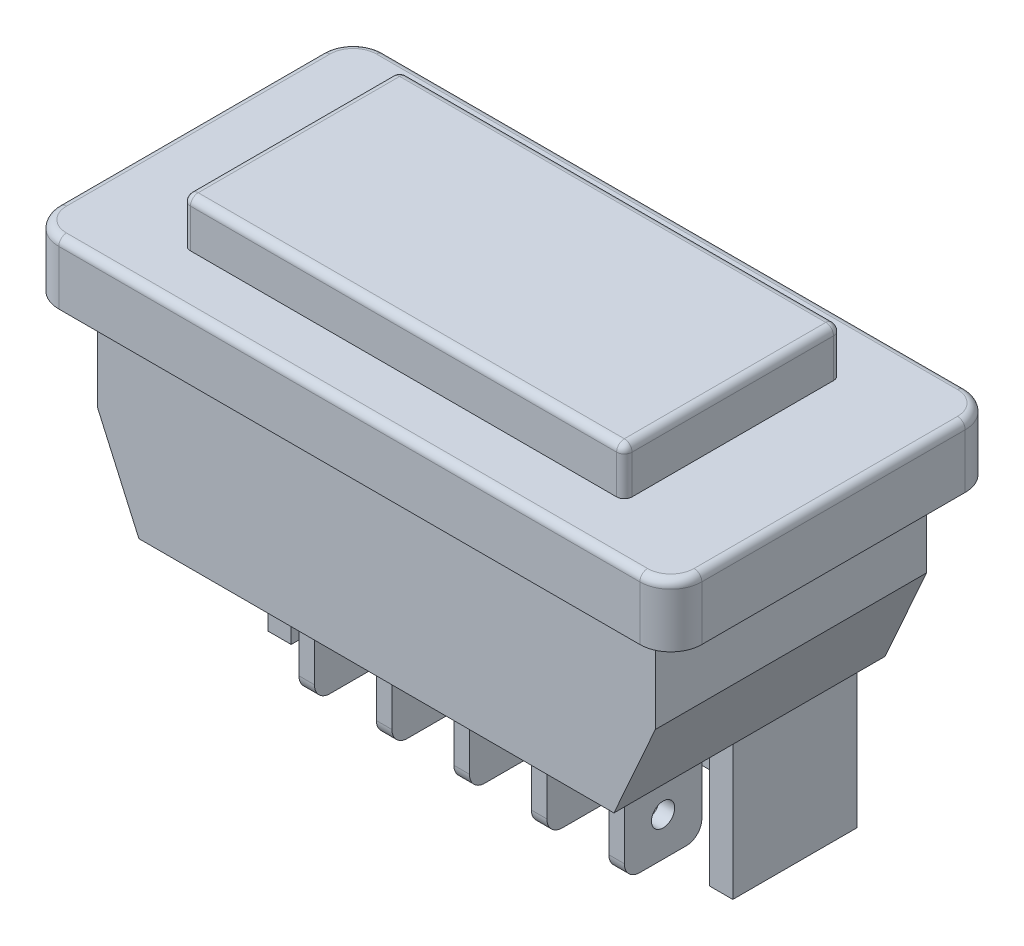
from build123d import *

# Parameters (mm, degrees)
SKETCH_1_W             = 41.5
SKETCH_1_H             = 21
EXTRUDE_1_DEPTH        = 4
FILLET_1_R             = 2
FILLET_2_R             = 0.5
SKETCH_2_W             = 28.5
SKETCH_2_H             = 14
EXTRUDE_2_DEPTH        = 3
FILLET_3_R             = 0.5
SKETCH_3_W             = 36
SKETCH_3_H             = 17.5
EXTRUDE_3_DEPTH        = 12
CHAMFER_1_SIZE         = 6
CHAMFER_1_SIZE2        = 2.671372112
CHAMFER_1_PART_2_SIZE  = 6
CHAMFER_1_PART_2_SIZE2 = 2.671372112
SKETCH_4_W             = 1
SKETCH_4_H             = 5
EXTRUDE_4_DEPTH        = 9
FILLET_4_R             = 1
SKETCH_5_R             = 0.75
CUT_EXTRUDE_1_DEPTH    = 21


with BuildPart() as part:
    # Эскиз1 → Бобышка-Вытянуть1 (new body)
    with BuildSketch(Plane(origin=(0, 0, 0), x_dir=(1, 0, 0), z_dir=(0, 1, 0))):
        Rectangle(SKETCH_1_W, SKETCH_1_H)
    extrude(amount=EXTRUDE_1_DEPTH)

    # Скругление1
    fillet_1_edges = [part.edges().sort_by_distance(p)[0] for p in [
        (20.75, 2, 10.5),
        (-20.75, 2, 10.5),
        (-20.75, 2, -10.5),
        (20.75, 2, -10.5),
    ]]
    fillet(fillet_1_edges, radius=FILLET_1_R)

    # Скругление2
    fillet_2_edges = [part.edges().sort_by_distance(p)[0] for p in [
        (-20.75, 4, 0),
        (0, 4, -10.5),
        (20.75, 4, 0),
        (0, 4, 10.5),
        (-20.164213562, 4, 9.914213562),
        (20.164213562, 4, 9.914213562),
        (20.164213562, 4, -9.914213562),
        (-20.164213562, 4, -9.914213562),
    ]]
    fillet(fillet_2_edges, radius=FILLET_2_R)

    # Эскиз2 → Бобышка-Вытянуть2 (add)
    with BuildSketch(Plane(origin=(0, 4, 0), x_dir=(1, 0, 0), z_dir=(0, 1, 0))):
        Rectangle(SKETCH_2_W, SKETCH_2_H)
    extrude(amount=EXTRUDE_2_DEPTH)

    # Скругление3
    fillet_3_edges = [part.edges().sort_by_distance(p)[0] for p in [
        (14.25, 5.5, 7),
        (14.25, 5.5, -7),
        (-14.25, 5.5, -7),
        (-14.25, 5.5, 7),
        (14.25, 7, 0),
        (0, 7, -7),
        (-14.25, 7, 0),
        (0, 7, 7),
    ]]
    fillet(fillet_3_edges, radius=FILLET_3_R)

    # Эскиз3 → Бобышка-Вытянуть3 (add)
    with BuildSketch(Plane.XZ):
        Rectangle(SKETCH_3_W, SKETCH_3_H)
    extrude(amount=EXTRUDE_3_DEPTH)

    # Фаска1
    chamfer_1_edges = [part.edges().sort_by_distance(p)[0] for p in [
        (18, -12, 0),
    ]]
    chamfer_1_side = [part.faces().sort_by_distance(p)[0] for p in [
        (18, -6, 0),
    ]]
    chamfer(chamfer_1_edges, length=CHAMFER_1_SIZE, length2=CHAMFER_1_SIZE2, reference=chamfer_1_side[0])

    # Фаска1 part 2
    chamfer_1_part_2_edges = [part.edges().sort_by_distance(p)[0] for p in [
        (-18, -12, 0),
    ]]
    chamfer_1_part_2_side = [part.faces().sort_by_distance(p)[0] for p in [
        (-18, -6, 0),
    ]]
    chamfer(chamfer_1_part_2_edges, length=CHAMFER_1_PART_2_SIZE, length2=CHAMFER_1_PART_2_SIZE2, reference=chamfer_1_part_2_side[0])

    # Эскиз4 → Бобышка-Вытянуть4 (add)
    with BuildSketch(Plane.XZ.offset(12)):
        Polygon((13.5, 0.75), (15, 0.75), (15, -7.25), (-15, -7.25), (-15, 0.75), (-13.5, 0.75), (-13.5, -5.75), (13.5, -5.75), align=None)
        with Locations((5, 0.75)):
            Rectangle(SKETCH_4_W, SKETCH_4_H)
        with Locations((0, 0.75)):
            Rectangle(SKETCH_4_W, SKETCH_4_H)
        with Locations((10, 0.75)):
            Rectangle(SKETCH_4_W, SKETCH_4_H)
        with Locations((-5, 0.75)):
            Rectangle(SKETCH_4_W, SKETCH_4_H)
        with Locations((-10, 0.75)):
            Rectangle(SKETCH_4_W, SKETCH_4_H)
    extrude(amount=EXTRUDE_4_DEPTH)

    # Скругление4
    fillet_4_edges = [part.edges().sort_by_distance(p)[0] for p in [
        (5, -21, -1.75),
        (5, -21, 3.25),
        (0, -21, 3.25),
        (0, -21, -1.75),
        (10, -21, -1.75),
        (10, -21, 3.25),
        (-5, -21, -1.75),
        (-5, -21, 3.25),
        (-10, -21, -1.75),
        (-10, -21, 3.25),
    ]]
    fillet(fillet_4_edges, radius=FILLET_4_R)

    # Эскиз5 → Вырез-Вытянуть1 (cut)
    with BuildSketch(Plane.ZY.offset(10.5)):
        with Locations((0.75, -18.5)):
            Circle(SKETCH_5_R)
    extrude(amount=-CUT_EXTRUDE_1_DEPTH, mode=Mode.SUBTRACT)


solid = part.part
